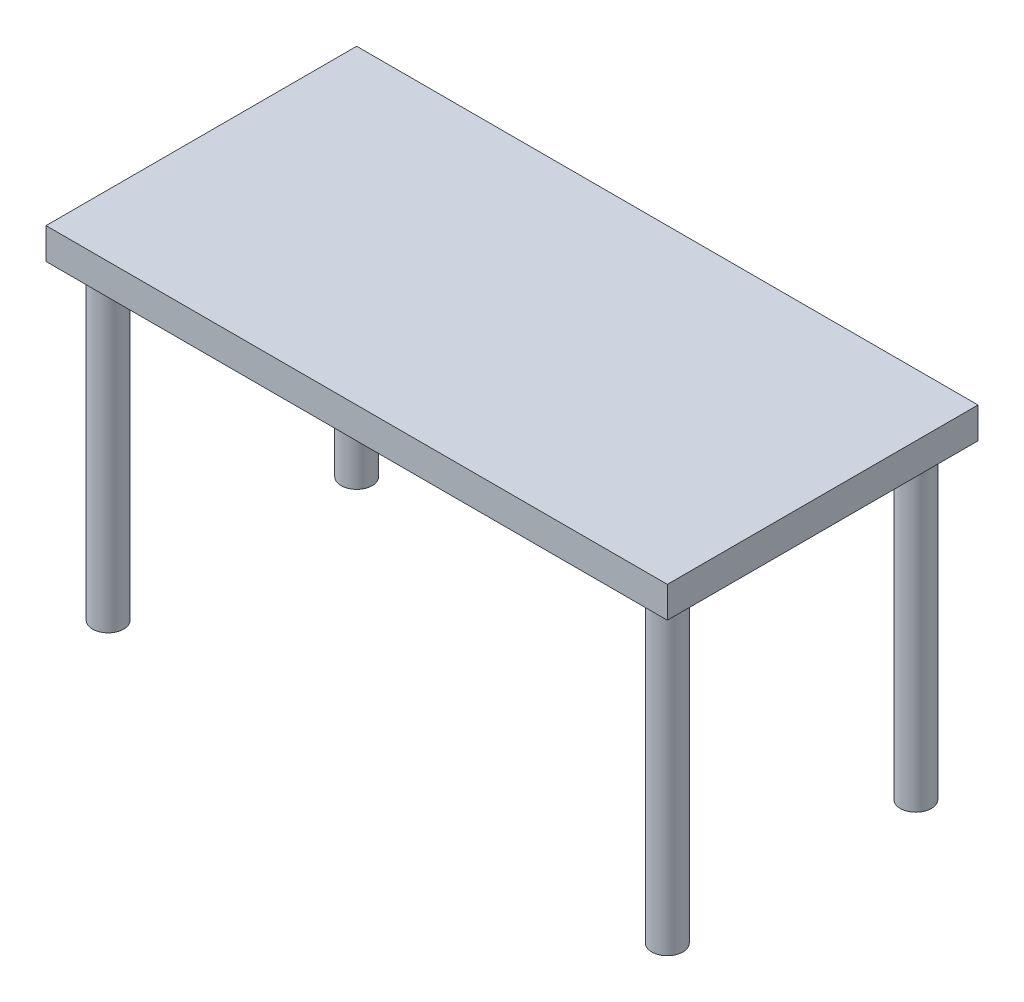
from build123d import *

# Parameters (mm, degrees)
SKETCH1_W               = 1000
SKETCH1_H               = 500
BOSS_EXTRUDE1_DEPTH     = 100
SKETCH2_R               = 50
BOSS_EXTRUDE2_DEPTH     = 1000
MIRROR2_COPY_1_SKETCH_W = 1000
MIRROR2_COPY_1_SKETCH_H = 500
MIRROR2_COPY_1_DEPTH    = 100
MIRROR2_COPY_2_SKETCH_R = 50
MIRROR2_COPY_2_DEPTH    = 1000


with BuildPart() as part:
    # Sketch1 → Boss-Extrude1 (new body)
    with BuildSketch(Plane(origin=(0, 0, 0), x_dir=(1, 0, 0), z_dir=(0, 1, 0))):
        with Locations((500, 250)):
            Rectangle(SKETCH1_W, SKETCH1_H)
    boss_extrude1 = extrude(amount=-BOSS_EXTRUDE1_DEPTH)

    # Sketch2 → Boss-Extrude2 (add)
    with BuildSketch(Plane.XZ.offset(100)):
        with Locations((900, -400)):
            Circle(SKETCH2_R)
    boss_extrude2 = extrude(amount=BOSS_EXTRUDE2_DEPTH)

    # Mirror1: Boss-Extrude1, Boss-Extrude2 across plane
    add(boss_extrude1.mirror(Plane(origin=(0, 0, 0), x_dir=(0, 0, 1), z_dir=(1, 0, 0))))
    add(boss_extrude2.mirror(Plane(origin=(0, 0, 0), x_dir=(0, 0, 1), z_dir=(1, 0, 0))))

    # Mirror2: Boss-Extrude2, Boss-Extrude1 across plane
    add(boss_extrude2.mirror(Plane.XY))
    add(boss_extrude1.mirror(Plane.XY))

    # Mirror2 copy 1 sketch → Mirror2 copy 1 (add)
    with BuildSketch(Plane(origin=(0, 0, 0), x_dir=(-1, 0, 0), z_dir=(0, 1, 0))):
        with Locations((500, 250)):
            Rectangle(MIRROR2_COPY_1_SKETCH_W, MIRROR2_COPY_1_SKETCH_H)
    extrude(amount=-MIRROR2_COPY_1_DEPTH)

    # Mirror2 copy 2 sketch → Mirror2 copy 2 (add)
    with BuildSketch(Plane(origin=(0, -100, 0), x_dir=(-1, 0, 0), z_dir=(0, -1, 0))):
        with Locations((900, -400)):
            Circle(MIRROR2_COPY_2_SKETCH_R)
    extrude(amount=MIRROR2_COPY_2_DEPTH)


solid = part.part
